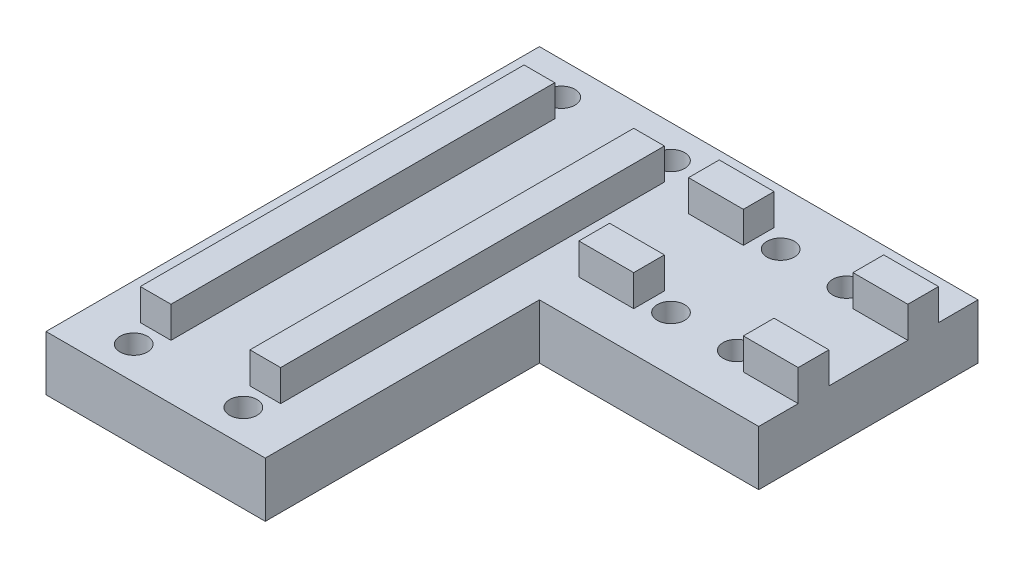
from build123d import *

# Parameters (mm, degrees)
SALIENTE_EXTRUIR1_DEPTH = 10
SALIENTE_EXTRUIR2_DEPTH = 90
SALIENTE_EXTRUIR3_DEPTH = 50
CROQUIS6_W              = 56.928573576
CROQUIS6_H              = 55.923287038
CORTAR_EXTRUIR2_DEPTH   = 30
CROQUIS5_W              = 40
CROQUIS5_H              = 10
CROQUIS5_W_2            = 10
CROQUIS5_H_2            = 40
CORTAR_EXTRUIR1_DEPTH   = 5.7
CROQUIS7_R              = 2.5
CORTAR_EXTRUIR3_DEPTH   = 11
SKETCH1_W               = 156.521822712
SKETCH1_H               = 40.193765496
CUT_EXTRUDE1_DEPTH      = 40


with BuildPart() as part:
    # Croquis1 → Saliente-Extruir1 (new body)
    with BuildSketch(Plane(origin=(0, 0, 0), x_dir=(1, 0, 0), z_dir=(0, 1, 0))):
        Polygon((25, 20), (-65, 20), (-65, -20), (-15, -20), (-15, -70), (25, -70), (25, -20), align=None)
    extrude(amount=SALIENTE_EXTRUIR1_DEPTH)

    # Croquis2 → Saliente-Extruir2 (add, through all)
    with BuildSketch(Plane.XY.offset(70)):
        Polygon((12.2, 9.987376579), (12.2, 15.7), (17.8, 15.7), (17.8, 9.987376579), (15, 9.987376579), align=None)
        Polygon((-7.8, 9.987376579), (-7.8, 15.7), (-2.2, 15.7), (-2.2, 9.987376579), (-5, 9.987376579), align=None)
    extrude(amount=-SALIENTE_EXTRUIR2_DEPTH)

    # Croquis3 → Saliente-Extruir3 (add)
    with BuildSketch(Plane.ZY.offset(65)):
        Polygon((7.2, 10), (7.2, 15.7), (12.8, 15.7), (12.8, 10), (10, 10), align=None)
        Polygon((-12.8, 10), (-12.8, 15.7), (-7.2, 15.7), (-7.2, 10), (-10, 10), align=None)
    extrude(amount=-SALIENTE_EXTRUIR3_DEPTH)

    # Croquis6 → Cortar-Extruir2 (cut)
    with BuildSketch(Plane.ZY.offset(65)):
        Rectangle(CROQUIS6_W, CROQUIS6_H)
    extrude(amount=-CORTAR_EXTRUIR2_DEPTH, mode=Mode.SUBTRACT)

    # Croquis5 → Cortar-Extruir1 (cut)
    with BuildSketch(Plane(origin=(0, 15.7, 0), x_dir=(1, 0, 0), z_dir=(0, 1, 0))):
        with Locations((5, -65)):
            Rectangle(CROQUIS5_W, CROQUIS5_H)
        with Locations((5, 15)):
            Rectangle(CROQUIS5_W, CROQUIS5_H)
        with Locations((-30, 0)):
            Rectangle(CROQUIS5_W_2, CROQUIS5_H_2)
    extrude(amount=-CORTAR_EXTRUIR1_DEPTH, mode=Mode.SUBTRACT)

    # Croquis7 → Cortar-Extruir3 (cut, through all)
    with BuildSketch(Plane(origin=(0, 10, 0), x_dir=(1, 0, 0), z_dir=(0, 1, 0))):
        with Locations((-29, 10)):
            Circle(CROQUIS7_R)
        with Locations((-29, -10)):
            Circle(CROQUIS7_R)
        with Locations((15, 14)):
            Circle(CROQUIS7_R)
        with Locations((-5, 14)):
            Circle(CROQUIS7_R)
        with Locations((-5, -64)):
            Circle(CROQUIS7_R)
        with Locations((15, -64)):
            Circle(CROQUIS7_R)
    extrude(amount=-CORTAR_EXTRUIR3_DEPTH, mode=Mode.SUBTRACT)

    # Mirror1: part across plane


with BuildPart() as part_1:
    add(part.part)
    add(part.part.mirror(Plane.ZY.offset(35)))

    # Sketch1 → Cut-Extrude1 (cut)
    with BuildSketch(Plane(origin=(25, 0, 0), x_dir=(0, 0, -1), z_dir=(1, 0, 0))):
        Rectangle(SKETCH1_W, SKETCH1_H)
    extrude(amount=-CUT_EXTRUDE1_DEPTH, mode=Mode.SUBTRACT)


solid = part_1.part
